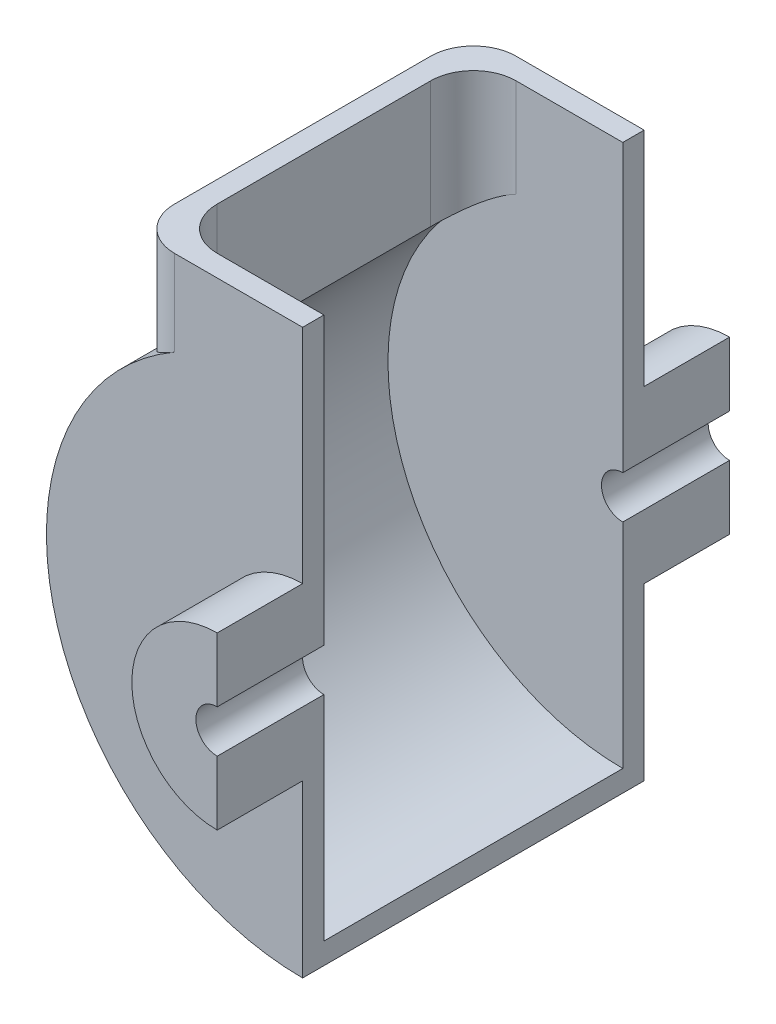
from build123d import *

# Parameters (mm, degrees)
DODANIE_WYCI_GNI_CIE1_DEPTH       = 25
DODANIE_WYCI_GNI_CIE2_DEPTH       = 5
WYCI_GNI_CIE_CIENKA_CIANKA1_DEPTH = 70
ZAOKR_GLENIE2_R                   = 10


with BuildPart() as part:
    # Szkic1 → Dodanie-wyciągnięcie1 (new body)
    with BuildSketch(Plane.XY):
        with BuildLine():
            Line((0, -5), (0, -20))
            ThreePointArc((0, -20), (-20, 0), (0, 20))
            Line((0, 20), (0, 5))
            ThreePointArc((0, 5), (-5, 0), (0, -5))
        make_face()
    extrude(amount=DODANIE_WYCI_GNI_CIE1_DEPTH)

    # Szkic2 → Dodanie-wyciągnięcie2 (add)
    with BuildSketch(Plane.XY):
        with BuildLine():
            Line((0, 20), (0, 72))
            Line((0, 72), (-40, 72))
            Line((-40, 72), (-40, 44.72135955))
            ThreePointArc((-40, 44.72135955), (-56.050341538, -21.409325386), (0, -60))
            Line((0, -60), (0, -20))
            ThreePointArc((0, -20), (-20, 0), (0, 20))
        make_face()
    extrude(amount=DODANIE_WYCI_GNI_CIE2_DEPTH)


with BuildPart() as body_2:
    # Lustro3: mirrored copy
    add(part.part.mirror(Plane(origin=(0, 0, -35), x_dir=(1, 0, 0), z_dir=(0, 0, -1))))


with BuildPart() as part_1:
    add(part.part)

    add(body_2.part)  # Wyciągnięcie-cienka ścianka1 merges body 2
    # Szkic5 → Wyciągnięcie-cienka ścianka1 (add)
    with BuildSketch(Plane(origin=(0, 0, 0), x_dir=(-1, 0, 0), z_dir=(0, 0, -1))):
        with BuildLine():
            Line((40, 72), (40, 44.72135955))
            ThreePointArc((40, 44.72135955), (56.050341538, -21.409325386), (0, -60))
            Line((0, -60), (0, -55))
            ThreePointArc((0, -55), (51.76124215, -18.594994247), (35, 42.426406871))
            Line((35, 42.426406871), (35, 72))
            Line((35, 72), (40, 72))
        make_face()
    extrude(amount=WYCI_GNI_CIE_CIENKA_CIANKA1_DEPTH)

    # Zaokrąglenie2
    zaokr_glenie2_edges = [part_1.edges().sort_by_distance(p)[0] for p in [
        (-40, 58.360679775, 5),
        (-35, 57.213203436, -70),
        (-35, 57.213203436, 0),
        (-40, 58.360679775, -75),
    ]]
    fillet(zaokr_glenie2_edges, radius=ZAOKR_GLENIE2_R)


solid = part_1.part
